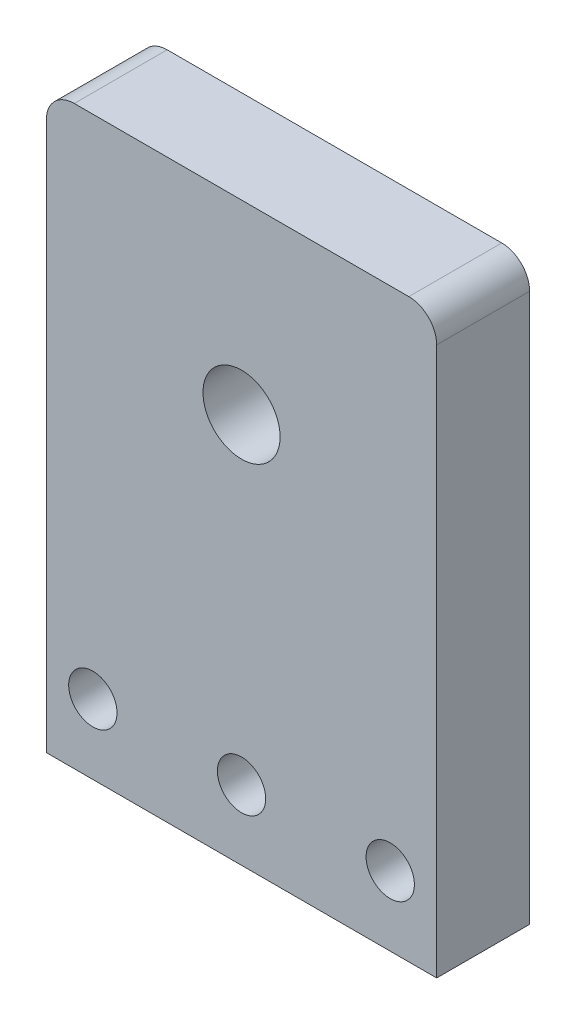
from build123d import *

# Parameters (mm, degrees)
SKETCH1_W           = 42
SKETCH1_H           = 62
SKETCH1_R           = 4.15
BOSS_EXTRUDE1_DEPTH = 10
FILLET1_R           = 3
SKETCH2_R           = 2.6
CUT_EXTRUDE1_DEPTH  = 11


with BuildPart() as part:
    # Sketch1 → Boss-Extrude1 (new body)
    with BuildSketch(Plane.XY):
        with Locations((21, 31)):
            Rectangle(SKETCH1_W, SKETCH1_H)
        with Locations((21, 42)):
            Circle(SKETCH1_R, mode=Mode.SUBTRACT)
    extrude(amount=BOSS_EXTRUDE1_DEPTH)

    # Fillet1
    fillet1_edges = [part.edges().sort_by_distance(p)[0] for p in [
        (0, 62, 5),
        (42, 62, 5),
    ]]
    fillet(fillet1_edges, radius=FILLET1_R)

    # Sketch2 → Cut-Extrude1 (cut, through all)
    with BuildSketch(Plane.XY.offset(10)):
        with Locations((5, 7.5)):
            Circle(SKETCH2_R)
        with Locations((21, 7.5)):
            Circle(SKETCH2_R)
        with Locations((37, 7.5)):
            Circle(SKETCH2_R)
    extrude(amount=-CUT_EXTRUDE1_DEPTH, mode=Mode.SUBTRACT)


solid = part.part
